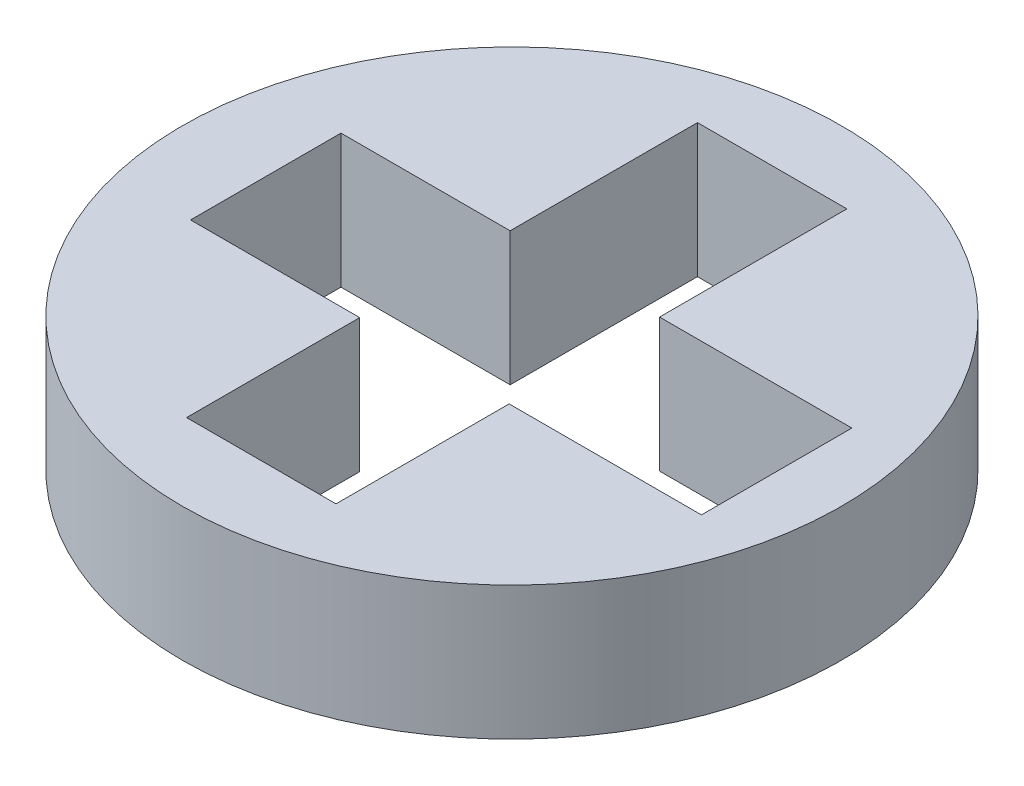
from build123d import *

# Parameters (mm, degrees)
SKETCH1_R           = 2.47
BOSS_EXTRUDE1_DEPTH = 1


with BuildPart() as part:
    # Sketch1 → Boss-Extrude1 (new body)
    with BuildSketch(Plane(origin=(0, 0, 0), x_dir=(1, 0, 0), z_dir=(0, 1, 0))):
        Circle(SKETCH1_R)
        Polygon((-1.827803458, -0.580830581), (-1.827803458, 0.546492653), (-0.56, 0.546492653), (-0.56, 1.950438827), (0.56, 1.950438827), (0.56, 0.546492653), (2.001200092, 0.546492653), (2.001200092, -0.580830581), (0.56, -0.580830581), (0.56, -1.878564728), (-0.56, -1.878564728), (-0.56, -0.580830581), align=None, mode=Mode.SUBTRACT)
    extrude(amount=BOSS_EXTRUDE1_DEPTH)


solid = part.part
